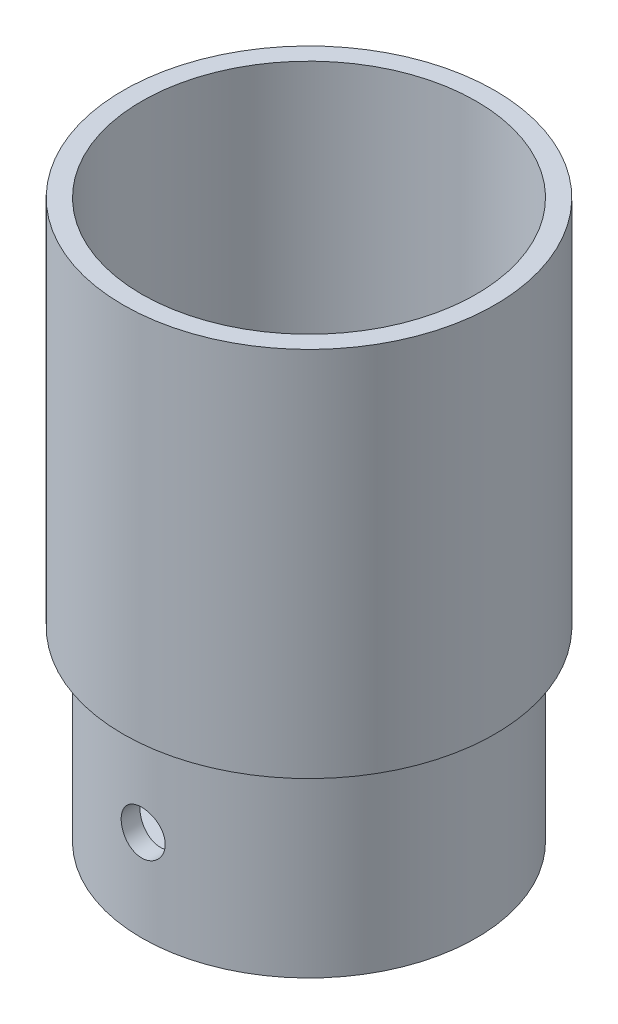
from build123d import *

# Parameters (mm, degrees)
CROQUIS1_R                 = 45
SALIENTE_EXTRUIR1_DEPTH    = 50
CROQUIS2_R                 = 40
CORTAR_EXTRUIR1_DEPTH      = 40
CROQUIS3_R                 = 6.541345014
CORTAR_EXTRUIR2_DEPTH      = 40
CROQUIS4_W                 = 7.058156528
CROQUIS4_H                 = 15.437867096
SALIENTE_EXTRUIR3_DEPTH    = 10
CROQUIS6_R                 = 5.921699686
CORTAR_EXTRUIR4_DEPTH      = 46
CORTAR_EXTRUIR4_DEPTH_BACK = 46
CROQUIS9_R                 = 50
SALIENTE_EXTRUIR5_DEPTH    = 100
CROQUIS10_R                = 45
CORTAR_EXTRUIR6_DEPTH      = 100


with BuildPart() as part:
    # Croquis1 → Saliente-Extruir1 (new body)
    with BuildSketch(Plane(origin=(0, 0, 0), x_dir=(1, 0, 0), z_dir=(0, 1, 0))):
        Circle(CROQUIS1_R)
    extrude(amount=SALIENTE_EXTRUIR1_DEPTH)

    # Croquis2 → Cortar-Extruir1 (cut)
    with BuildSketch(Plane(origin=(0, 50, 0), x_dir=(1, 0, 0), z_dir=(0, 1, 0))):
        Circle(CROQUIS2_R)
    extrude(amount=-CORTAR_EXTRUIR1_DEPTH, mode=Mode.SUBTRACT)

    # Croquis3 → Cortar-Extruir2 (cut)
    with BuildSketch(Plane.XZ):
        Circle(CROQUIS3_R)
    extrude(amount=-CORTAR_EXTRUIR2_DEPTH, mode=Mode.SUBTRACT)

    # Croquis4 → Saliente-Extruir3 (add)
    with BuildSketch(Plane.XZ):
        with Locations((-6.541345014, 0)):
            Rectangle(CROQUIS4_W, CROQUIS4_H)
    extrude(amount=-SALIENTE_EXTRUIR3_DEPTH)

    # Croquis6 → Cortar-Extruir4 (cut, two sides)
    with BuildSketch(Plane.XY) as cortar_extruir4_sk:
        with Locations((0, 24.563563624)):
            Circle(CROQUIS6_R)
    extrude(amount=CORTAR_EXTRUIR4_DEPTH, mode=Mode.SUBTRACT)
    extrude(cortar_extruir4_sk.sketch, amount=-CORTAR_EXTRUIR4_DEPTH_BACK, mode=Mode.SUBTRACT)

    # Croquis9 → Saliente-Extruir5 (add)
    with BuildSketch(Plane(origin=(0, 50, 0), x_dir=(1, 0, 0), z_dir=(0, 1, 0))):
        Circle(CROQUIS9_R)
    extrude(amount=SALIENTE_EXTRUIR5_DEPTH)

    # Croquis10 → Cortar-Extruir6 (cut)
    with BuildSketch(Plane(origin=(0, 150, 0), x_dir=(1, 0, 0), z_dir=(0, 1, 0))):
        Circle(CROQUIS10_R)
    extrude(amount=-CORTAR_EXTRUIR6_DEPTH, mode=Mode.SUBTRACT)


solid = part.part
